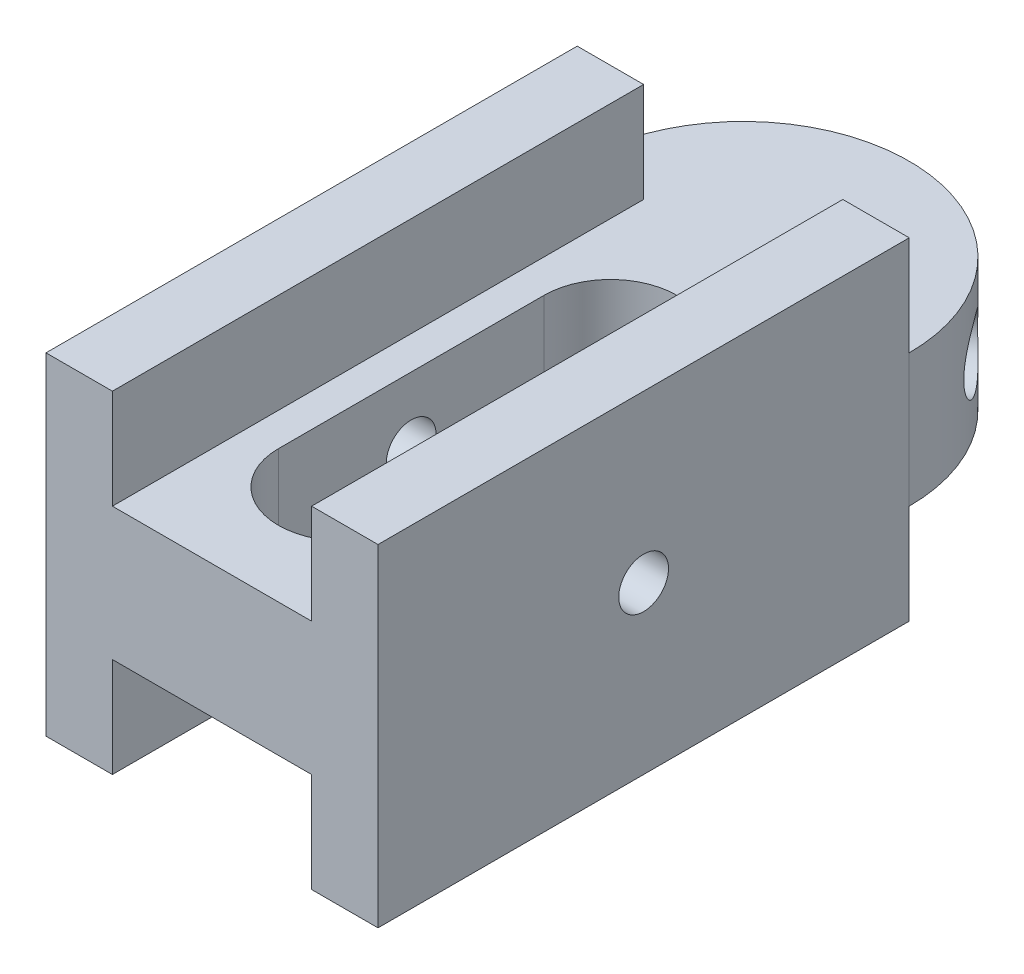
from build123d import *

# Parameters (mm, degrees)
SKETCH1_W                = 15.875
SKETCH1_H                = 15.875
BOSS_EXTRUDE1_DEPTH      = 25.4
BOSS_EXTRUDE3_DEPTH      = 3.175
BOSS_EXTRUDE3_DEPTH_BACK = 3.175
SKETCH4_R                = 1.190625
CUT_EXTRUDE1_DEPTH       = 16.875
SKETCH8_R                = 1.5875
CUT_EXTRUDE3_DEPTH       = 7.9375
SKETCH7_R                = 1.5875
CUT_EXTRUDE4_DEPTH       = 7.9375
SKETCH9_W                = 9.525
SKETCH9_H                = 4.7625
CUT_EXTRUDE5_DEPTH       = 26.4
CUT_EXTRUDE6_DEPTH       = 12.1125


with BuildPart() as part:
    # Sketch1 → Boss-Extrude1 (new body)
    with BuildSketch(Plane.XY):
        Rectangle(SKETCH1_W, SKETCH1_H)
    extrude(amount=BOSS_EXTRUDE1_DEPTH)

    # Sketch3 → Boss-Extrude3 (add, two sides)
    with BuildSketch(Plane(origin=(0, 0, 0), x_dir=(1, 0, 0), z_dir=(0, 1, 0))) as boss_extrude3_sk:
        with BuildLine():
            Line((-7.9375, 0), (7.9375, 0))
            ThreePointArc((7.9375, 0), (0, 7.9375), (-7.9375, 0))
        make_face()
    extrude(amount=BOSS_EXTRUDE3_DEPTH)
    extrude(boss_extrude3_sk.sketch, amount=-BOSS_EXTRUDE3_DEPTH_BACK)

    # Sketch4 → Cut-Extrude1 (cut, through all)
    with BuildSketch(Plane(origin=(7.9375, 0, 0), x_dir=(0, 0, -1), z_dir=(1, 0, 0))):
        with Locations((-12.7, 0)):
            Circle(SKETCH4_R)
    extrude(amount=-CUT_EXTRUDE1_DEPTH, mode=Mode.SUBTRACT)

    # Sketch8 → Cut-Extrude3 (cut)
    with BuildSketch(Plane(origin=(6.380613831, 0, -4.72140587), x_dir=(-0.594822787, 0, -0.803856861), z_dir=(0.803856861, 0, -0.594822787))):
        Circle(SKETCH8_R)
    extrude(amount=-CUT_EXTRUDE3_DEPTH, mode=Mode.SUBTRACT)

    # Sketch7 → Cut-Extrude4 (cut)
    with BuildSketch(Plane(origin=(-4.72140587, 0, -6.380613831), x_dir=(0.803856861, 0, -0.594822787), z_dir=(0.594822787, 0, 0.803856861))):
        Circle(SKETCH7_R)
    extrude(amount=CUT_EXTRUDE4_DEPTH, mode=Mode.SUBTRACT)

    # Sketch9 → Cut-Extrude5 (cut, through all)
    with BuildSketch(Plane(origin=(0, 0, 0), x_dir=(-1, 0, 0), z_dir=(0, 0, -1))):
        with Locations((0, 5.55625)):
            Rectangle(SKETCH9_W, SKETCH9_H)
        with Locations((0, -5.55625)):
            Rectangle(SKETCH9_W, SKETCH9_H)
    extrude(amount=-CUT_EXTRUDE5_DEPTH, mode=Mode.SUBTRACT)

    # Sketch10 → Cut-Extrude6 (cut, through all)
    with BuildSketch(Plane(origin=(0, -3.175, 0), x_dir=(-1, 0, 0), z_dir=(0, -1, 0))):
        with BuildLine():
            Line((-3.175, -19.05), (-3.175, -6.35))
            ThreePointArc((-3.175, -6.35), (0, -3.175), (3.175, -6.35))
            Line((3.175, -6.35), (3.175, -19.05))
            ThreePointArc((3.175, -19.05), (0, -22.225), (-3.175, -19.05))
        make_face()
    extrude(amount=-CUT_EXTRUDE6_DEPTH, mode=Mode.SUBTRACT)


solid = part.part
